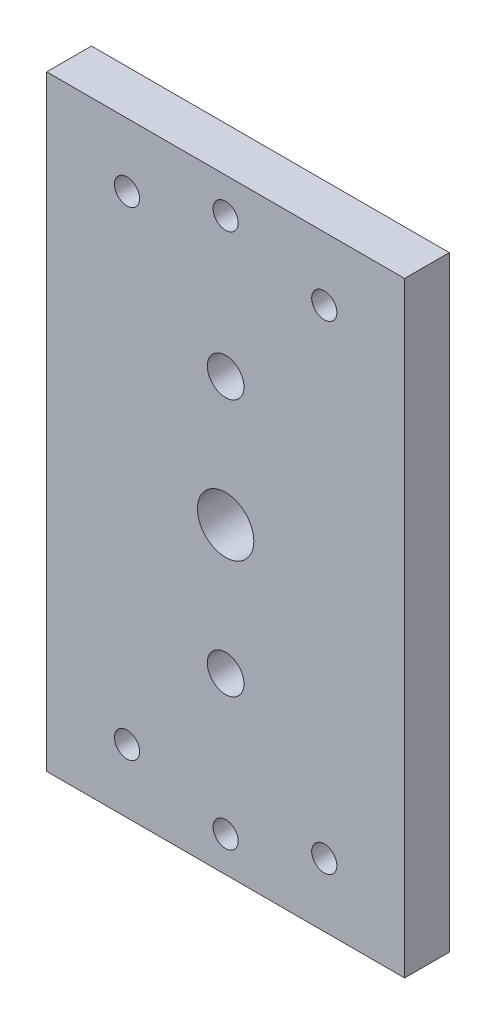
from build123d import *

# Parameters (mm, degrees)
CROQUIS1_W              = 50.8
CROQUIS1_H              = 86
SALIENTE_EXTRUIR1_DEPTH = 6.35
CROQUIS2_R              = 4
CROQUIS2_R_2            = 2.6
CORTAR_EXTRUIR1_DEPTH   = 6.35
CROQUIS3_R              = 1.785
CORTAR_EXTRUIR2_DEPTH   = 7.35


with BuildPart() as part:
    # Croquis1 → Saliente-Extruir1 (new body)
    with BuildSketch(Plane.XY):
        with Locations((25.4, 43)):
            Rectangle(CROQUIS1_W, CROQUIS1_H)
    extrude(amount=SALIENTE_EXTRUIR1_DEPTH)

    # Croquis2 → Cortar-Extruir1 (cut)
    with BuildSketch(Plane.XY.offset(6.35)):
        with Locations((25.4, 43)):
            Circle(CROQUIS2_R)
        with Locations((25.4, 61.25)):
            Circle(CROQUIS2_R_2)
        with Locations((25.4, 24.75)):
            Circle(CROQUIS2_R_2)
    extrude(amount=-CORTAR_EXTRUIR1_DEPTH, mode=Mode.SUBTRACT)

    # Croquis3 → Cortar-Extruir2 (cut, through all)
    with BuildSketch(Plane.XY.offset(6.35)):
        with Locations((25.4, 81)):
            Circle(CROQUIS3_R)
        with Locations((11.4, 77)):
            Circle(CROQUIS3_R)
        with Locations((39.4, 77)):
            Circle(CROQUIS3_R)
        with Locations((39.4, 9)):
            Circle(CROQUIS3_R)
        with Locations((11.4, 9)):
            Circle(CROQUIS3_R)
        with Locations((25.4, 5)):
            Circle(CROQUIS3_R)
    extrude(amount=-CORTAR_EXTRUIR2_DEPTH, mode=Mode.SUBTRACT)


solid = part.part
